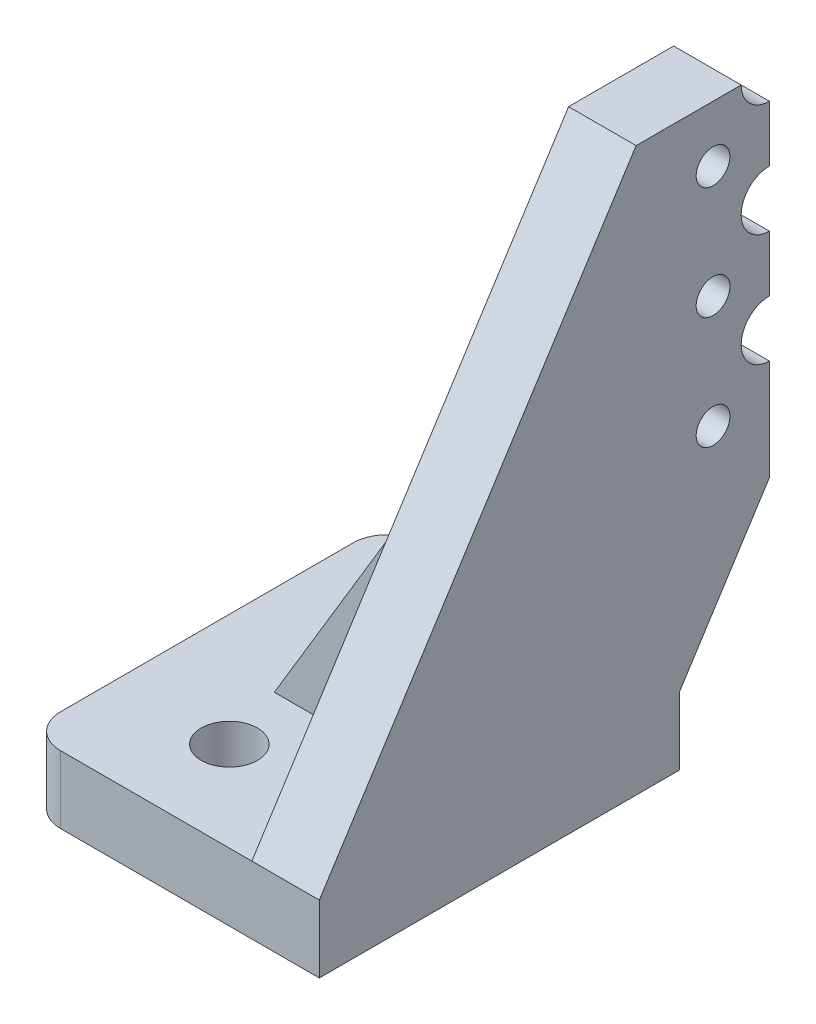
from build123d import *

# Parameters (mm, degrees)
SKETCH1_R          = 1.25
EXTRUDE1_DEPTH     = 3
SKETCH2_R          = 1.25
EXTRUDE2_DEPTH     = 3
EXTRUDE4_DEPTH     = 1
CUT_EXTRUDE1_REACH = 15
SKETCH6_R          = 0.75


with BuildPart() as part:
    # Sketch1 → Extrude1 (new body)
    with BuildSketch(Plane(origin=(0, 0, 0), x_dir=(0, 0, -1), z_dir=(1, 0, 0))):
        with BuildLine():
            Line((4, 30), (4, 15.5))
            Line((4, 15.5), (-4, 3))
            Line((-4, 3), (-4, 0))
            Line((-4, 0), (-20, 0))
            Line((-20, 0), (-20, 3))
            Line((-20, 3), (-4, 28))
            Line((-4, 28), (-4, 30))
            ThreePointArc((-4, 30), (0, 34), (4, 30))
        make_face()
        with Locations((0, 15)):
            Circle(SKETCH1_R, mode=Mode.SUBTRACT)
        with Locations((0, 20)):
            Circle(SKETCH1_R, mode=Mode.SUBTRACT)
        with Locations((0, 25)):
            Circle(SKETCH1_R, mode=Mode.SUBTRACT)
        with Locations((0, 30)):
            Circle(SKETCH1_R, mode=Mode.SUBTRACT)
    extrude(amount=-EXTRUDE1_DEPTH)

    # Sketch2 → Extrude2 (add)
    with BuildSketch(Plane.XZ):
        with BuildLine():
            Line((-3, 20), (-11.5, 20))
            ThreePointArc((-11.5, 20), (-12.560660172, 19.560660172), (-13, 18.5))
            Line((-13, 18.5), (-13, 5.5))
            ThreePointArc((-13, 5.5), (-12.560660172, 4.439339828), (-11.5, 4))
            Line((-11.5, 4), (-3, 4))
            Line((-3, 4), (-3, 20))
        make_face()
        with Locations(Location((-8, 16, 0), (0, 0, 270))):  # turned: the seam where the file's is
            Circle(SKETCH2_R, mode=Mode.SUBTRACT)
        with Locations(Location((-8, 8, 0), (0, 0, 270))):  # turned: the seam where the file's is
            Circle(SKETCH2_R, mode=Mode.SUBTRACT)
    extrude(amount=-EXTRUDE2_DEPTH)

    # Sketch5 → Extrude4 (add, symmetric)
    with BuildSketch(Plane.XY.offset(12)):
        Polygon((-3, 3), (-9, 3), (-3, 13), align=None)
    extrude(amount=EXTRUDE4_DEPTH, both=True)

    # Sketch6 → Cut-Extrude1 (cut, up to next)
    with BuildSketch(Plane(origin=(0, 0, 0), x_dir=(0, 0, -1), z_dir=(1, 0, 0)), mode=Mode.PRIVATE) as cut_extrude1_sk1:
        with Locations((-2.5, 12.5)):
            Circle(SKETCH6_R)
    cut_extrude1_tool1 = extrude(cut_extrude1_sk1.sketch, amount=-CUT_EXTRUDE1_REACH, mode=Mode.PRIVATE) & part.part
    add(cut_extrude1_tool1.solids().sort_by_distance((0, 12.5, 2.5))[0], mode=Mode.SUBTRACT)
    # Sketch6 → Cut-Extrude1 (cut, up to next)
    with BuildSketch(Plane(origin=(0, 0, 0), x_dir=(0, 0, -1), z_dir=(1, 0, 0)), mode=Mode.PRIVATE) as cut_extrude1_sk2:
        with Locations((-2.5, 22.5)):
            Circle(SKETCH6_R)
    cut_extrude1_tool2 = extrude(cut_extrude1_sk2.sketch, amount=-CUT_EXTRUDE1_REACH, mode=Mode.PRIVATE) & part.part
    add(cut_extrude1_tool2.solids().sort_by_distance((0, 22.5, 2.5))[0], mode=Mode.SUBTRACT)
    # Sketch6 → Cut-Extrude1 (cut, up to next)
    with BuildSketch(Plane(origin=(0, 0, 0), x_dir=(0, 0, -1), z_dir=(1, 0, 0)), mode=Mode.PRIVATE) as cut_extrude1_sk3:
        with Locations((-2.5, 17.5)):
            Circle(SKETCH6_R)
    cut_extrude1_tool3 = extrude(cut_extrude1_sk3.sketch, amount=-CUT_EXTRUDE1_REACH, mode=Mode.PRIVATE) & part.part
    add(cut_extrude1_tool3.solids().sort_by_distance((0, 17.5, 2.5))[0], mode=Mode.SUBTRACT)
    # Sketch6 → Cut-Extrude1 (cut, up to next)
    with BuildSketch(Plane(origin=(0, 0, 0), x_dir=(0, 0, -1), z_dir=(1, 0, 0)), mode=Mode.PRIVATE) as cut_extrude1_sk4:
        Polygon((0, 0), (0, 25), (-8, 25), (-8, 35), (7, 35), (7, 0), align=None)
    cut_extrude1_tool4 = extrude(cut_extrude1_sk4.sketch, amount=-CUT_EXTRUDE1_REACH, mode=Mode.PRIVATE) & part.part
    add(cut_extrude1_tool4.solids().sort_by_distance((0, 20.576923, -1.653846))[0], mode=Mode.SUBTRACT)


solid = part.part
